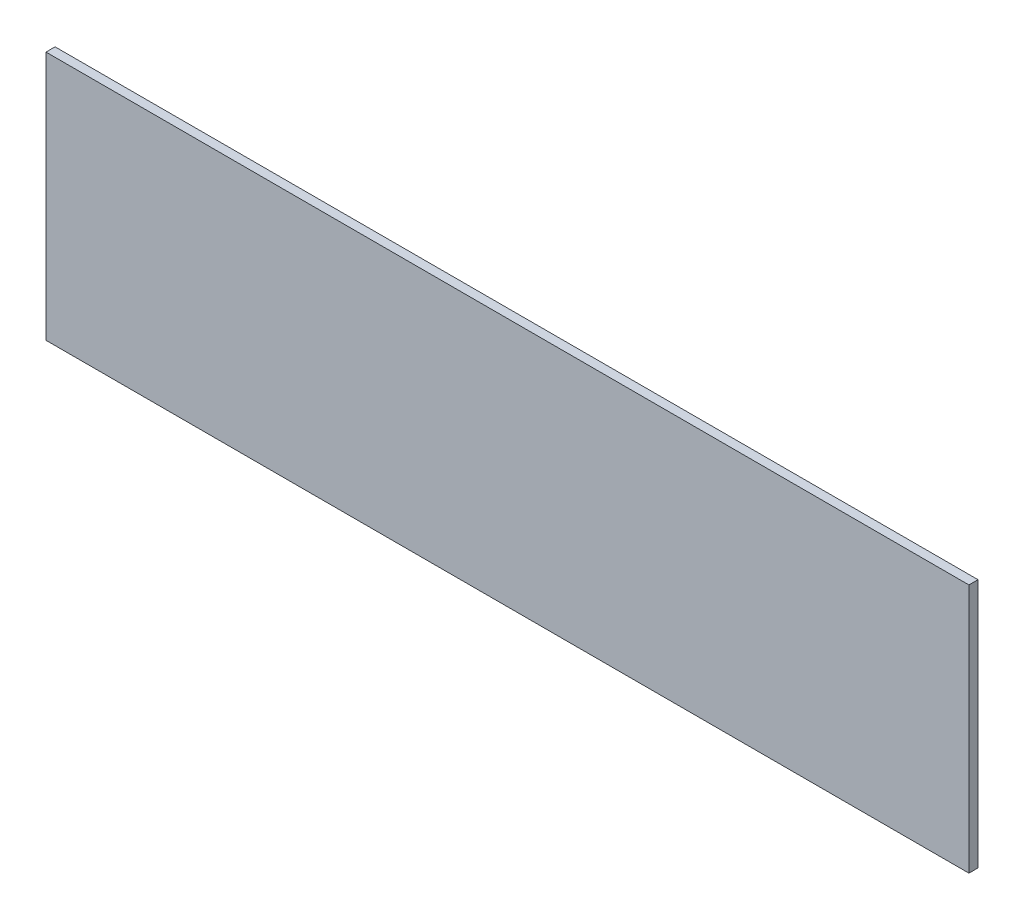
from build123d import *

# Parameters (mm, degrees)
CROQUIS1_W              = 305
CROQUIS1_H              = 82.5
SALIENTE_EXTRUIR1_DEPTH = 3


with BuildPart() as part:
    # Croquis1 → Saliente-Extruir1 (new body)
    with BuildSketch(Plane.XY):
        with Locations((152.5, 41.25)):
            Rectangle(CROQUIS1_W, CROQUIS1_H)
    extrude(amount=SALIENTE_EXTRUIR1_DEPTH)


solid = part.part
